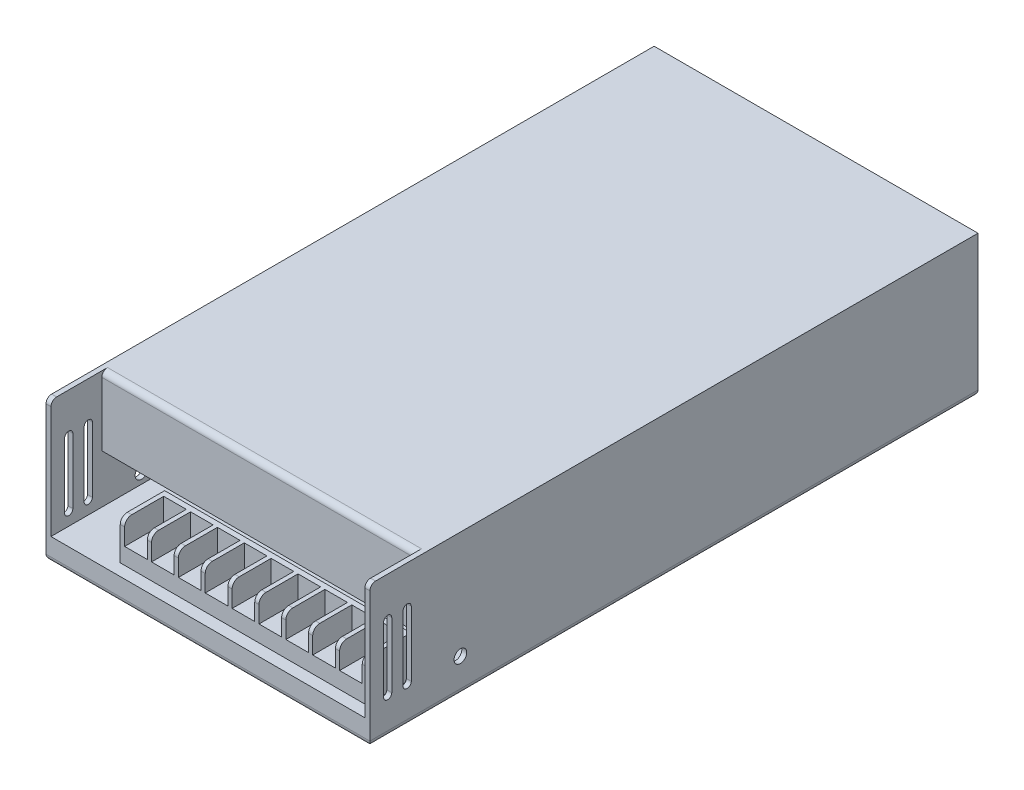
from build123d import *

# Parameters (mm, degrees)
SKETCH1_W                     = 114.5
SKETCH1_H                     = 215
BOSS_EXTRUDE1_DEPTH           = 41.75
BOSS_EXTRUDE1_DEPTH_BACK      = 8.25
SKETCH2_W                     = 111
SKETCH2_H                     = 41.75
CUT_EXTRUDE1_DEPTH            = 18
CUT_EXTRUDE2_DEPTH            = 115.5
FILLET1_R                     = 2
SKETCH4_W                     = 87.05
SKETCH4_H                     = 13.8
BOSS_EXTRUDE2_DEPTH           = 14.25
SKETCH7_W                     = 111
SKETCH7_H                     = 17.25
CUT_EXTRUDE4_DEPTH            = 195.25
FILLET2_R                     = 2.5
SKETCH6_W                     = 8
SKETCH6_H                     = 8.45
CUT_EXTRUDE3_DEPTH            = 13.8
SKETCH9_W                     = 87.05
SKETCH9_H                     = 13.75
BOSS_EXTRUDE6_DEPTH           = 1.9
LPATTERN1_COUNT               = 9
LPATTERN1_PITCH               = 9.5
M3_CLEARANCE_HOLE2_AT_2_COUNT = 2
M3_CLEARANCE_HOLE2_AT_2_PITCH = 95
M3_CLEARANCE_HOLE2_AT_3_COUNT = 2
M3_CLEARANCE_HOLE2_AT_3_PITCH = 201.544194905
M3_CLEARANCE_HOLE2_AT_4_COUNT = 2
M3_CLEARANCE_HOLE2_AT_4_PITCH = 177.75


with BuildPart() as part:
    # Sketch1 → Boss-Extrude1 (new body, two sides)
    with BuildSketch(Plane(origin=(0, 0, 0), x_dir=(1, 0, 0), z_dir=(0, 1, 0))) as boss_extrude1_sk:
        with Locations((0, 89.5)):
            Rectangle(SKETCH1_W, SKETCH1_H)
    extrude(amount=BOSS_EXTRUDE1_DEPTH)
    extrude(boss_extrude1_sk.sketch, amount=-BOSS_EXTRUDE1_DEPTH_BACK)

    # Sketch2 → Cut-Extrude1 (cut)
    with BuildSketch(Plane.XY.offset(18)):
        with Locations((0, 20.875)):
            Rectangle(SKETCH2_W, SKETCH2_H)
    extrude(amount=-CUT_EXTRUDE1_DEPTH, mode=Mode.SUBTRACT)

    # Sketch3 → Cut-Extrude2 (cut, through all)
    with BuildSketch(Plane(origin=(57.25, 0, 0), x_dir=(0, 0, -1), z_dir=(1, 0, 0))):
        with BuildLine():
            Line((-10.26, 27.7), (-10.26, 4.7))
            ThreePointArc((-10.26, 4.7), (-11.71, 3.25), (-13.16, 4.7))
            Line((-13.16, 4.7), (-13.16, 27.7))
            ThreePointArc((-13.16, 27.7), (-11.71, 29.15), (-10.26, 27.7))
        make_face()
        with BuildLine():
            Line((-3.36, 27.7), (-3.36, 4.7))
            ThreePointArc((-3.36, 4.7), (-4.81, 3.25), (-6.26, 4.7))
            Line((-6.26, 4.7), (-6.26, 27.7))
            ThreePointArc((-6.26, 27.7), (-4.81, 29.15), (-3.36, 27.7))
        make_face()
    extrude(amount=-CUT_EXTRUDE2_DEPTH, mode=Mode.SUBTRACT)

    # Fillet1
    fillet1_edges = [part.edges().sort_by_distance(p)[0] for p in [
        (57.25, -8.25, -89.5),
        (-56.375, 41.75, 18),
        (0, -8.25, -197),
        (56.375, 41.75, 18),
        (0, 41.75, 0),
        (-57.25, -8.25, -89.5),
        (0, -8.25, 18),
    ]]
    fillet(fillet1_edges, radius=FILLET1_R)

    # Sketch7 → Cut-Extrude4 (cut)
    with BuildSketch(Plane.XY):
        with Locations((0, 8.625)):
            Rectangle(SKETCH7_W, SKETCH7_H)
    extrude(amount=-CUT_EXTRUDE4_DEPTH, mode=Mode.SUBTRACT)

    # Sketch13 → M3 Clearance Hole2 (revolve, cut)
    with BuildSketch(Plane(origin=(-47.5, -8.25, -8.75), x_dir=(0, 0, -1), z_dir=(1, 0, 0))):
        Polygon((0, 0), (0, 3.021463052), (1.7, 2), (1.7, 0), align=None)
    m3_clearance_hole2 = revolve(axis=Axis((-47.5, -14.6, -8.75), (0, 1, 0)), mode=Mode.SUBTRACT)

    # M3 Clearance Hole2 at 2: M3 Clearance Hole2 ×2
    with Locations(*[(i * M3_CLEARANCE_HOLE2_AT_2_PITCH, 0, 0) for i in range(1, M3_CLEARANCE_HOLE2_AT_2_COUNT)]):
        add(m3_clearance_hole2, mode=Mode.SUBTRACT)

    # M3 Clearance Hole2 at 3: M3 Clearance Hole2 ×2
    with Locations(*[Vector(0.471360637, 0, -0.881940559) * (i * M3_CLEARANCE_HOLE2_AT_3_PITCH) for i in range(1, M3_CLEARANCE_HOLE2_AT_3_COUNT)]):
        add(m3_clearance_hole2, mode=Mode.SUBTRACT)

    # M3 Clearance Hole2 at 4: M3 Clearance Hole2 ×2
    with Locations(*[(0, 0, -i * M3_CLEARANCE_HOLE2_AT_4_PITCH) for i in range(1, M3_CLEARANCE_HOLE2_AT_4_COUNT)]):
        add(m3_clearance_hole2, mode=Mode.SUBTRACT)

    # Sketch15 → M4 Clearance Hole1 (revolve, cut)
    with BuildSketch(Plane(origin=(57.25, 3.75, -14), x_dir=(0, 0, -1), z_dir=(0, 1, 0))):
        Polygon((0, 0), (0, 3.351936393), (2.25, 2), (2.25, 0), align=None)
    m4_clearance_hole1 = revolve(axis=Axis((63.6, 3.75, -14), (-1, 0, 0)), mode=Mode.SUBTRACT)

    # M4 Hole Other Side: M4 Clearance Hole1 across plane
    add(m4_clearance_hole1.mirror(Plane(origin=(0, 0, 0), x_dir=(0, 0, 1), z_dir=(1, 0, 0))), mode=Mode.SUBTRACT)


with BuildPart() as body_2:
    # Sketch4 → Boss-Extrude2 (new body)
    with BuildSketch(Plane(origin=(0, 0, 0), x_dir=(-1, 0, 0), z_dir=(0, 1, 0))):
        with Locations((-8.325, 6.9)):
            Rectangle(SKETCH4_W, SKETCH4_H)
    extrude(amount=BOSS_EXTRUDE2_DEPTH)

    # Fillet2
    fillet2_edges = [body_2.edges().sort_by_distance(p)[0] for p in [
        (8.325, 14.25, 13.8),
    ]]
    fillet(fillet2_edges, radius=FILLET2_R)

    # Sketch6 → Cut-Extrude3 (cut)
    with BuildSketch(Plane.XY.offset(13.8)):
        with Locations((46.35, 10.025)):
            Rectangle(SKETCH6_W, SKETCH6_H)
    cut_extrude3 = extrude(amount=-CUT_EXTRUDE3_DEPTH, mode=Mode.SUBTRACT)

    # Sketch9 → Boss-Extrude6 (add)
    with BuildSketch(Plane(origin=(0, 0, 0), x_dir=(-1, 0, 0), z_dir=(0, 0, -1))):
        with Locations((-8.325, 7.375)):
            Rectangle(SKETCH9_W, SKETCH9_H)
    extrude(amount=BOSS_EXTRUDE6_DEPTH)

    # LPattern1: Cut-Extrude3 ×9
    with Locations(*[(-i * LPATTERN1_PITCH, 0, 0) for i in range(1, LPATTERN1_COUNT)]):
        add(cut_extrude3, mode=Mode.SUBTRACT)


solid = Compound([part.part, body_2.part])
